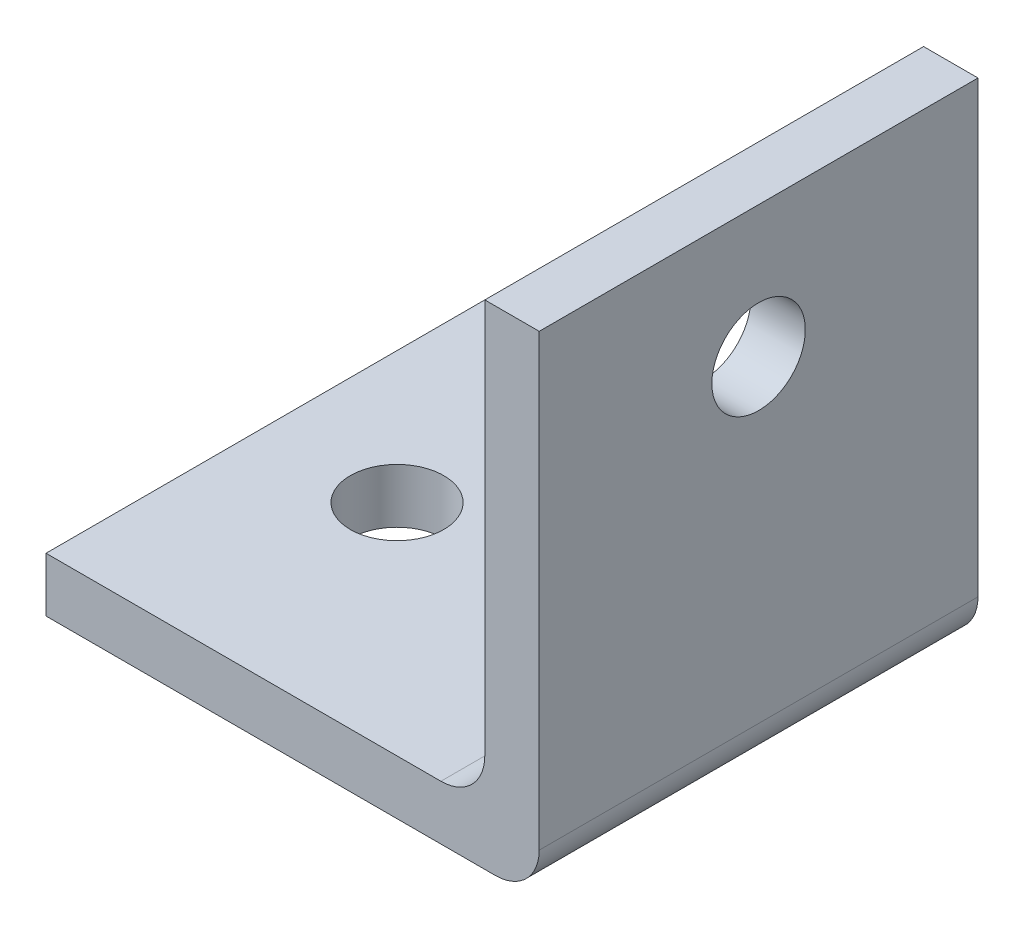
from build123d import *

# Parameters (mm, degrees)
BOSS_EXTRUDE1_DEPTH   = 12.7
FILLET1_R             = 1.27
F_6_32_TAPPED_HOLE1_D = 2.7051
F_6_32_TAPPED_HOLE2_D = 2.7051


with BuildPart() as part:
    # Sketch1 → Boss-Extrude1 (new body)
    with BuildSketch(Plane.XY):
        Polygon((0, 0), (14.2748, 0), (14.2748, 14.2748), (12.7, 14.2748), (12.7, 1.5748), (0, 1.5748), align=None)
    extrude(amount=BOSS_EXTRUDE1_DEPTH)

    # Fillet1
    fillet1_edges = [part.edges().sort_by_distance(p)[0] for p in [
        (12.7, 1.5748, 6.35),
        (14.2748, 0, 6.35),
    ]]
    fillet(fillet1_edges, radius=FILLET1_R)

    # #6-32 Tapped Hole1 (through all)
    with Locations(Plane.ZY.offset(-12.7)):
        with Locations((6.35, 10.4648)):
            Hole(F_6_32_TAPPED_HOLE1_D / 2)

    # #6-32 Tapped Hole2 (through all)
    with Locations(Plane(origin=(0, 1.5748, 0), x_dir=(1, 0, 0), z_dir=(0, 1, 0))):
        with Locations((3.81, -6.35)):
            Hole(F_6_32_TAPPED_HOLE2_D / 2)


solid = part.part
